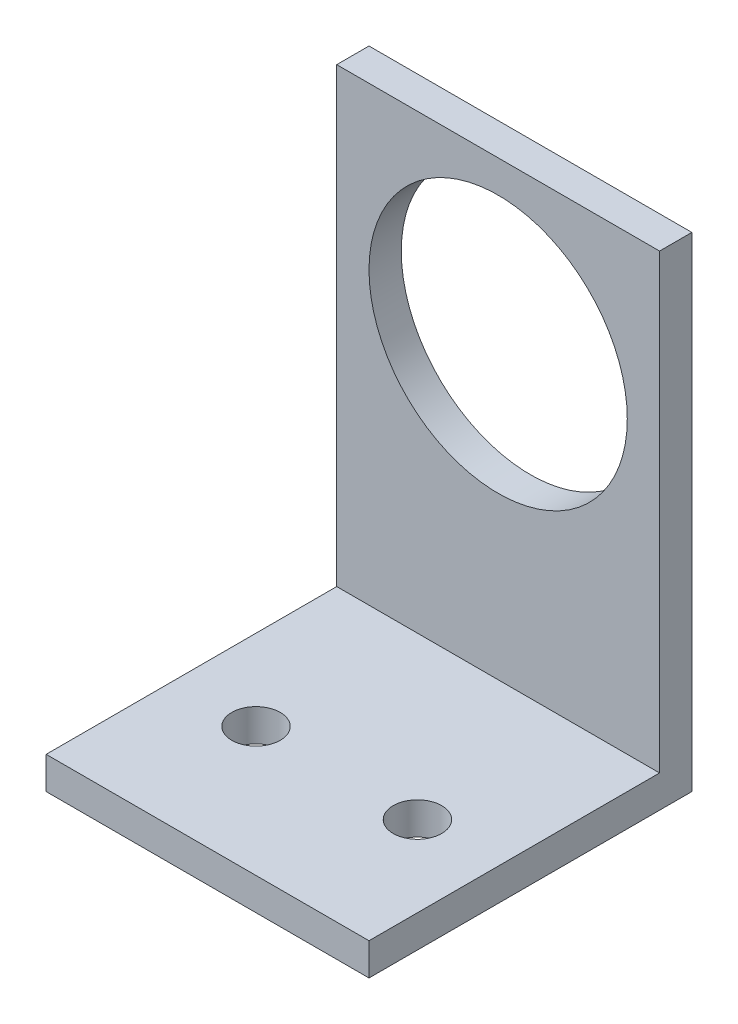
from build123d import *

# Parameters (mm, degrees)
SKETCH_1_W          = 20
SKETCH_1_H          = 38
EXTRUDE_1_DEPTH     = 3
SKETCH_2_W          = 20
SKETCH_2_H          = 3
EXTRUDE_2_DEPTH     = 35
SKETCH_4_R          = 1.5
CUT_EXTRUDE_2_DEPTH = 10
SKETCH_6_R          = 8
CUT_EXTRUDE_4_DEPTH = 10
SKETCH_7_W          = 48.70277248
SKETCH_7_H          = 15.025597173
CUT_EXTRUDE_5_DEPTH = 17
SKETCH_8_W          = 23.770758151
SKETCH_8_H          = 7.865139004
CUT_EXTRUDE_6_DEPTH = 8
SKETCH_9_W          = 25.851926442
SKETCH_9_H          = 19.370122162
CUT_EXTRUDE_7_DEPTH = 1
SKETCH_10_W         = 62.66737892
SKETCH_10_H         = 43.463838198
CUT_EXTRUDE_8_DEPTH = 1


with BuildPart() as part:
    # 草图1 → 凸台-拉伸1 (new body)
    with BuildSketch(Plane.XY):
        Rectangle(SKETCH_1_W, SKETCH_1_H)
    extrude(amount=EXTRUDE_1_DEPTH)

    # 草图2 → 凸台-拉伸2 (add)
    with BuildSketch(Plane.XY.offset(3)):
        with Locations((0, -17.5)):
            Rectangle(SKETCH_2_W, SKETCH_2_H)
    extrude(amount=EXTRUDE_2_DEPTH)

    # 草图4 → 切除-拉伸2 (cut)
    with BuildSketch(Plane(origin=(0, -16, 0), x_dir=(1, 0, 0), z_dir=(0, 1, 0))):
        with Locations((-5, -13)):
            Circle(SKETCH_4_R)
        with Locations((5, -13)):
            Circle(SKETCH_4_R)
    extrude(amount=-CUT_EXTRUDE_2_DEPTH, mode=Mode.SUBTRACT)

    # 草图6 → 切除-拉伸4 (cut)
    with BuildSketch(Plane(origin=(0, 0, 0), x_dir=(-1, 0, 0), z_dir=(0, 0, -1))):
        with Locations((0, 1)):
            Circle(SKETCH_6_R)
    extrude(amount=-CUT_EXTRUDE_4_DEPTH, mode=Mode.SUBTRACT)

    # 草图7 → 切除-拉伸5 (cut)
    with BuildSketch(Plane.XY.offset(38)):
        with Locations((-7.483280409, -20.314408955)):
            Rectangle(SKETCH_7_W, SKETCH_7_H)
    extrude(amount=-CUT_EXTRUDE_5_DEPTH, mode=Mode.SUBTRACT)

    # 草图8 → 切除-拉伸6 (cut)
    with BuildSketch(Plane(origin=(0, 19, 0), x_dir=(1, 0, 0), z_dir=(0, 1, 0))):
        with Locations((-0.181621183, -1.317277333)):
            Rectangle(SKETCH_8_W, SKETCH_8_H)
    extrude(amount=-CUT_EXTRUDE_6_DEPTH, mode=Mode.SUBTRACT)

    # 草图9 → 切除-拉伸7 (cut)
    with BuildSketch(Plane(origin=(0, -16, 0), x_dir=(1, 0, 0), z_dir=(0, 1, 0))):
        with Locations((2.925963221, -12.685061081)):
            Rectangle(SKETCH_9_W, SKETCH_9_H)
    extrude(amount=-CUT_EXTRUDE_7_DEPTH, mode=Mode.SUBTRACT)

    # 草图10 → 切除-拉伸8 (cut)
    with BuildSketch(Plane(origin=(0, 0, 0), x_dir=(-1, 0, 0), z_dir=(0, 0, -1))):
        with Locations((0.038577245, -3.3946505)):
            Rectangle(SKETCH_10_W, SKETCH_10_H)
    extrude(amount=-CUT_EXTRUDE_8_DEPTH, mode=Mode.SUBTRACT)


solid = part.part
